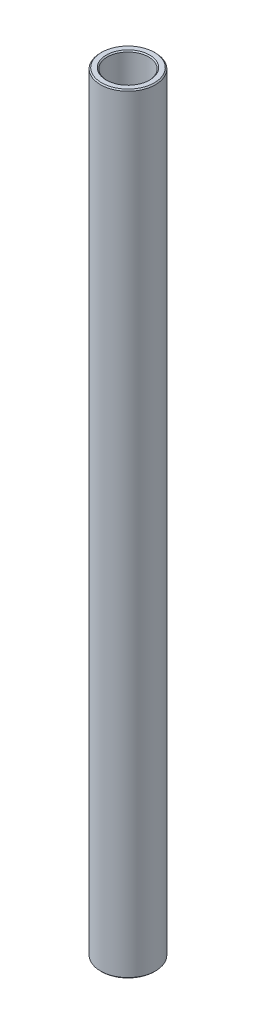
from build123d import *

# Parameters (mm, degrees)
SKETCH1_W     = 1.5875
SKETCH1_H     = 177.8
CHAMFER1_SIZE = 0.254


with BuildPart() as part:
    # Sketch1 → Revolve1 (revolve)
    with BuildSketch(Plane.XY):
        with Locations((5.55625, 0)):
            Rectangle(SKETCH1_W, SKETCH1_H)
    revolve(axis=Axis((0, 11.60859375, 0), (0, -1, 0)))

    # Chamfer1
    chamfer1_edges = [part.edges().sort_by_distance(p)[0] for p in [
        (-4.7625, -88.9, 0),
        (-6.35, -88.9, 0),
        (-6.35, 88.9, 0),
        (-4.7625, 88.9, 0),
    ]]
    chamfer(chamfer1_edges, length=CHAMFER1_SIZE)


solid = part.part
